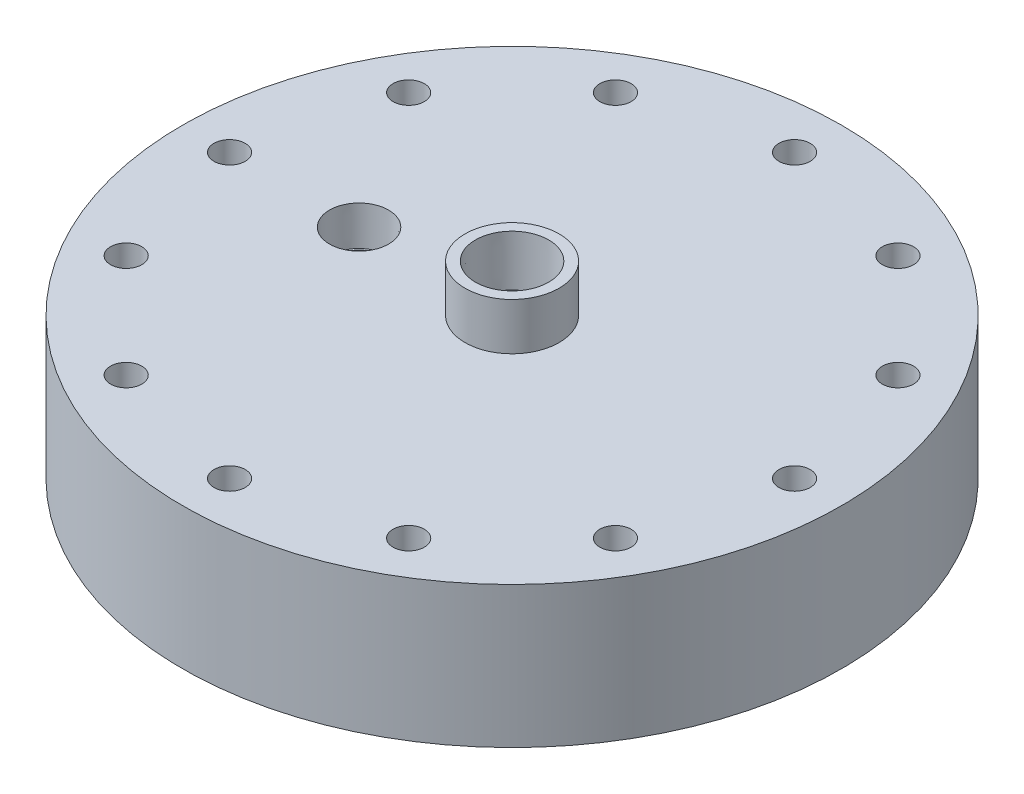
from build123d import *

# Parameters (mm, degrees)
F_5_16_CLEARANCE_HOLE1_D = 8.4328
CIRPATTERN1_COUNT        = 12


with BuildPart() as part:
    # Sketch1 → Revolve1 (revolve)
    with BuildSketch(Plane.XY):
        Polygon((-55.9435, 0), (-88.9, 0), (-88.9, 38.1), (-12.7, 38.1), (-12.7, 50.8), (0, 50.8), (0, 31.75), (-25.4, 31.75), (-25.4, 19.05), (-31.75, 19.05), (-31.75, 12.7), (-50.8, 12.7), (-50.8, 0), (-52.3875, 0), (-52.3875, 2.54), (-55.9435, 2.54), align=None)
    revolve(axis=Axis((0, 0, 0), (0, 1, 0)))

    # Sketch8 → 1/2 NPT Tapped Hole1 (revolve, cut)
    with BuildSketch(Plane(origin=(0, 50.8, 0), x_dir=(0, 0, 1), z_dir=(1, 0, 0))):
        Polygon((0, 0), (0, 50.8), (8.9281, 50.8), (8.9281, 13.462), (9.479726792, 13.462), (9.8827971, 0), align=None)
    revolve(axis=Axis((0, 57.15, 0), (0, -1, 0)), mode=Mode.SUBTRACT)

    # Sketch3 → 3/8 NPT Tapped Hole1 (revolve, cut)
    with BuildSketch(Plane(origin=(-41.275, 38.1, 0), x_dir=(0, 0, 1), z_dir=(1, 0, 0))):
        Polygon((0, 0), (0, 29.688582582), (7.1374, 25.4), (7.1374, 10.414), (7.653732494, 10.414), (7.9655416, 0), align=None)
    revolve(axis=Axis((-41.275, 44.45, 0), (0, -1, 0)), mode=Mode.SUBTRACT)

    # 5/16 Clearance Hole1 (through all)
    with Locations(Plane(origin=(0, 38.1, 0), x_dir=(1, 0, 0), z_dir=(0, 1, 0))):
        with Locations((-76.2, 0)):
            f_5_16_clearance_hole1 = Hole(F_5_16_CLEARANCE_HOLE1_D / 2)

    # CirPattern1: 5/16 Clearance Hole1 ×12 about axis
    cirpattern1_axis = Axis((0, 0, 0), (0, 1, 0))
    for i in range(1, CIRPATTERN1_COUNT):
        add(f_5_16_clearance_hole1.rotate(cirpattern1_axis, i * 360 / CIRPATTERN1_COUNT), mode=Mode.SUBTRACT)


solid = part.part
